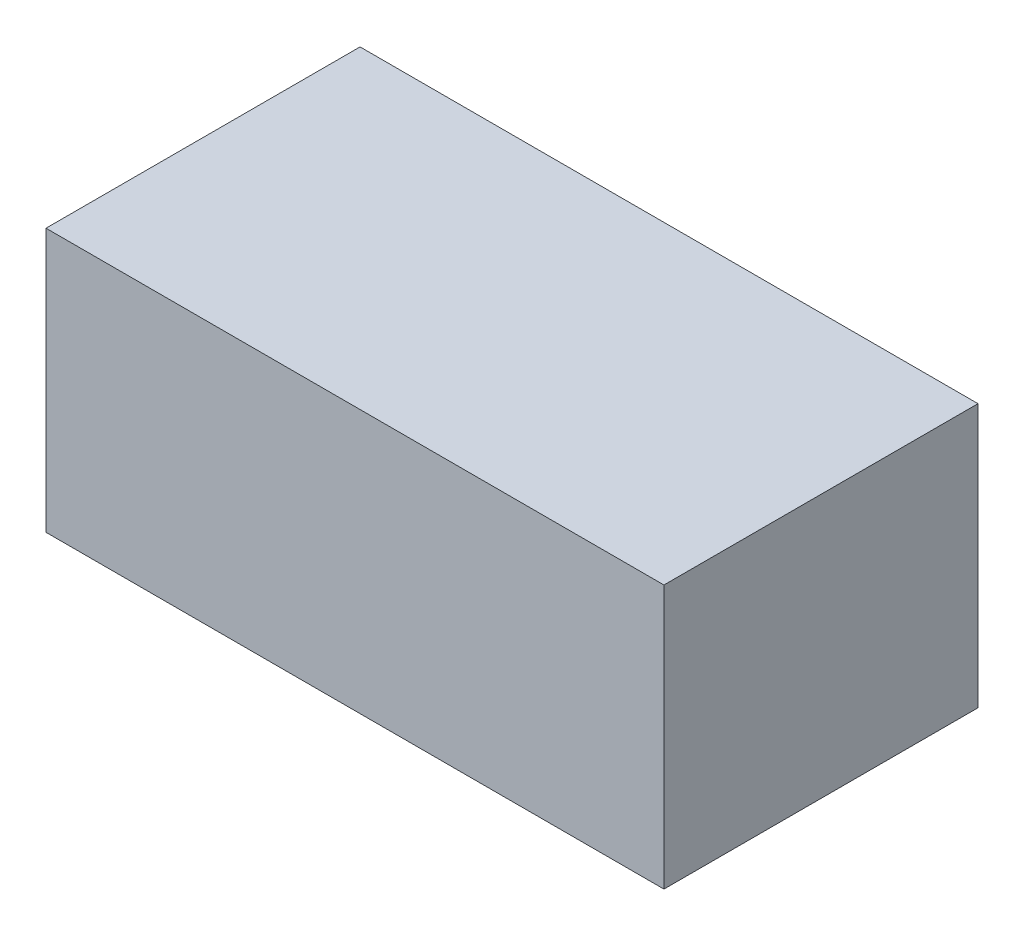
from build123d import *

# Parameters (mm, degrees)
SKETCH1_W           = 305
SKETCH1_H           = 155
BOSS_EXTRUDE1_DEPTH = 130


with BuildPart() as part:
    # Sketch1 → Boss-Extrude1 (new body)
    with BuildSketch(Plane(origin=(0, 0, 0), x_dir=(1, 0, 0), z_dir=(0, 1, 0))):
        with Locations((152.5, 77.5)):
            Rectangle(SKETCH1_W, SKETCH1_H)
    extrude(amount=BOSS_EXTRUDE1_DEPTH)


solid = part.part
